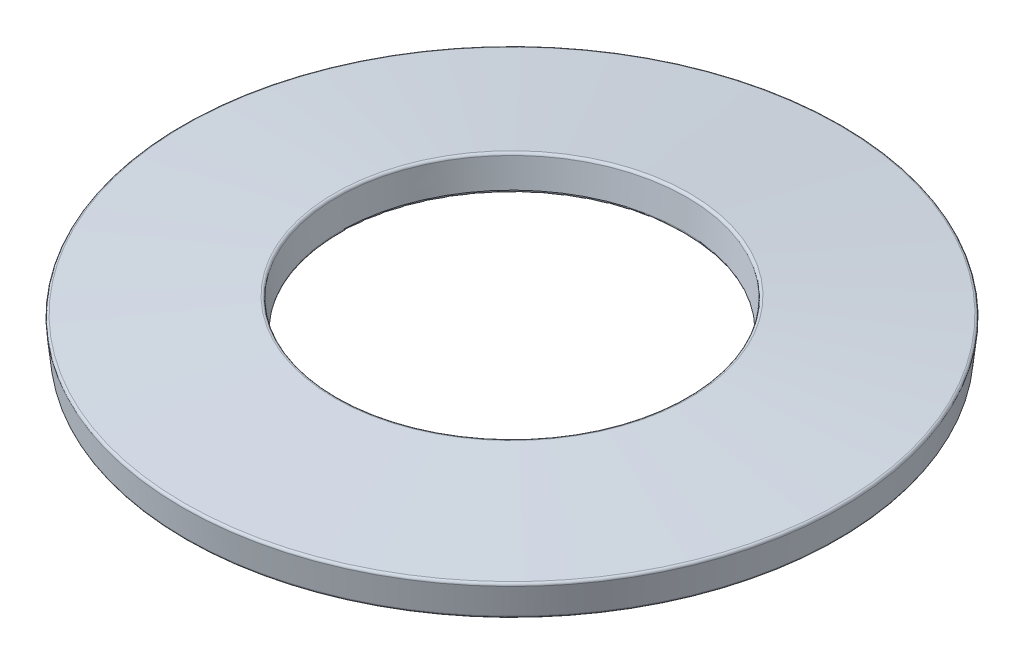
from build123d import *

# Parameters (mm, degrees)
FILLET1_R = 0.0375


with BuildPart() as part:
    # Sketch2 → Revolve1 (revolve)
    with BuildSketch(Plane.XY):
        Polygon((2.6, -0.122121355), (2.653575722, 0.375), (5, 0.122121355), (4.946424278, -0.375), align=None)
    revolve(axis=Axis((0, 0.375, 0), (0, -1, 0)))

    # Fillet1
    fillet1_edges = [part.edges().sort_by_distance(p)[0] for p in [
        (-4.946424278, -0.375, 0),
        (-5, 0.122121355, 0),
        (-2.653575722, 0.375, 0),
        (-2.6, -0.122121355, 0),
    ]]
    fillet(fillet1_edges, radius=FILLET1_R)


solid = part.part
